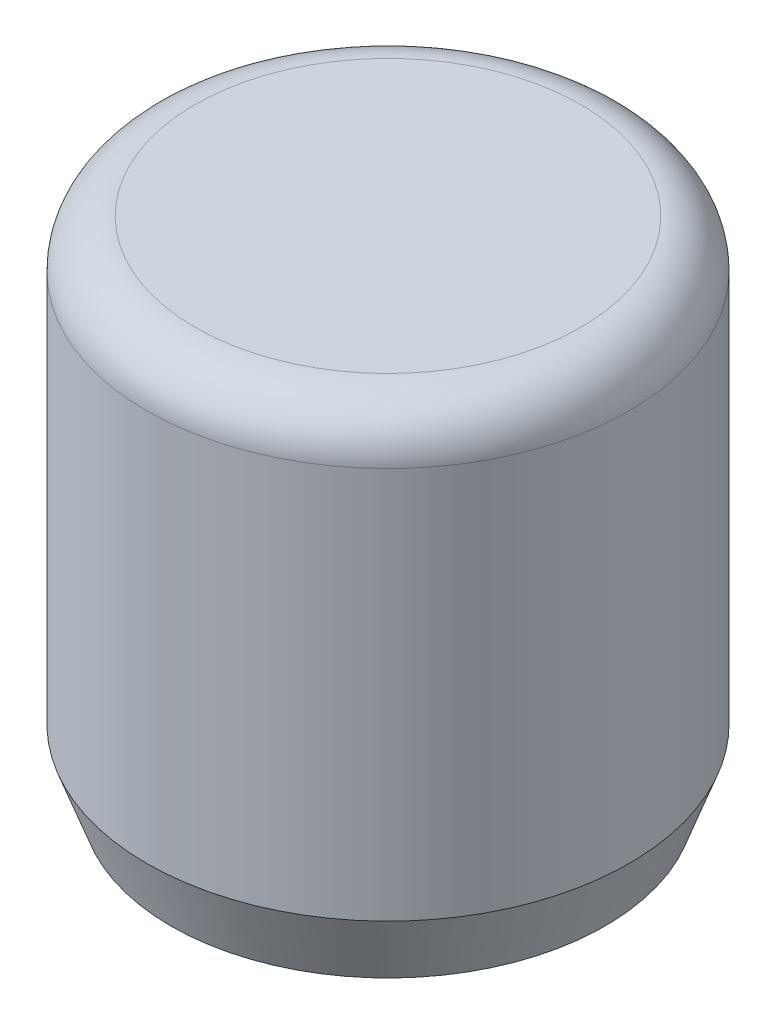
from build123d import *

# Parameters (mm, degrees)
SKETCH1_R           = 5
BOSS_EXTRUDE1_DEPTH = 10.5
SKETCH2_R           = 3
CUT_EXTRUDE1_DEPTH  = 6
FILLET1_R           = 1
CHAMFER1_SIZE       = 0.5
CHAMFER1_SIZE2      = 1.37373871


with BuildPart() as part:
    # Sketch1 → Boss-Extrude1 (new body)
    with BuildSketch(Plane(origin=(0, 0, 0), x_dir=(1, 0, 0), z_dir=(0, 1, 0))):
        Circle(SKETCH1_R)
    extrude(amount=BOSS_EXTRUDE1_DEPTH)

    # Sketch2 → Cut-Extrude1 (cut)
    with BuildSketch(Plane.XZ):
        Circle(SKETCH2_R)
    extrude(amount=-CUT_EXTRUDE1_DEPTH, mode=Mode.SUBTRACT)

    # Fillet1
    fillet1_edges = [part.edges().sort_by_distance(p)[0] for p in [
        (-5, 10.5, 0),
    ]]
    fillet(fillet1_edges, radius=FILLET1_R)

    # Chamfer1
    chamfer1_edges = [part.edges().sort_by_distance(p)[0] for p in [
        (-5, 0, 0),
    ]]
    chamfer1_side = [part.faces().sort_by_distance(p)[0] for p in [
        (-4.858578644, 0, 0),
    ]]
    chamfer(chamfer1_edges, length=CHAMFER1_SIZE, length2=CHAMFER1_SIZE2, reference=chamfer1_side[0])


solid = part.part
